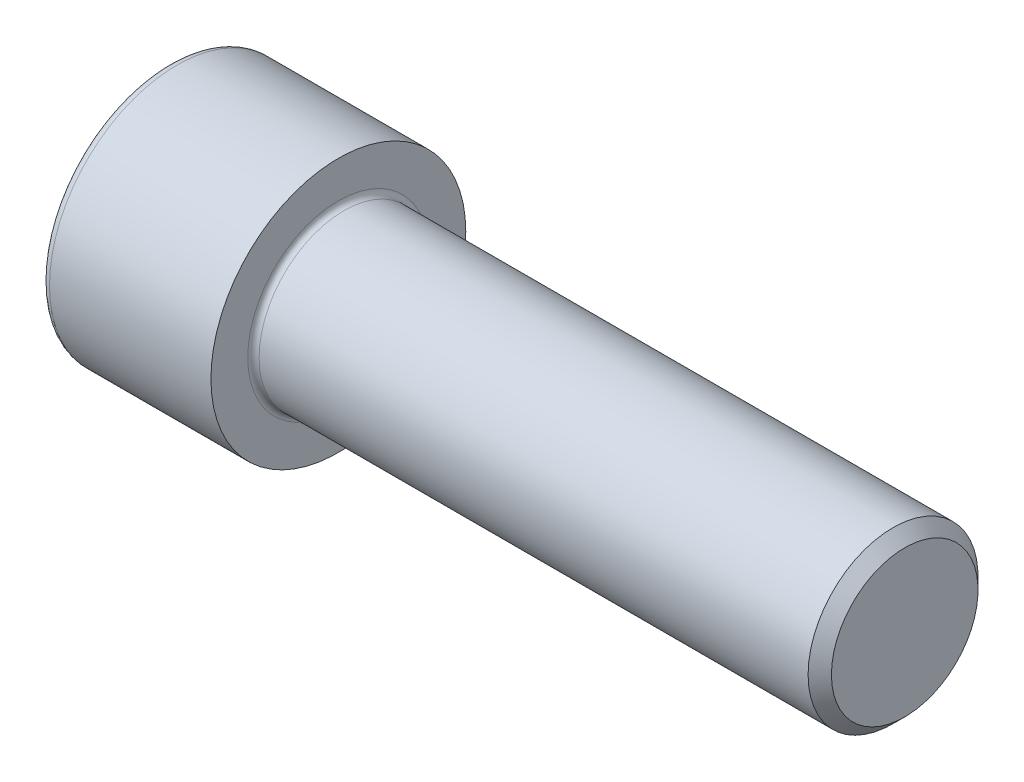
from build123d import *

# Parameters (mm, degrees)
FILLET1_R   = 0.8
FILLET2_R   = 1.2
HEX_2_DEPTH = 12.573


with BuildPart() as part:
    # BodySke → Base-Revolve (revolve)
    with BuildSketch(Plane.XY):
        Polygon((0, 0), (0, 18), (24, 18), (24, 12), (102.352, 12), (104, 10.352), (104, 0), align=None)
    revolve(axis=Axis((-31.75, 0, 0), (1, 0, 0)))

    # Fillet1
    fillet1_edges = [part.edges().sort_by_distance(p)[0] for p in [
        (24, -12, 0),
    ]]
    fillet(fillet1_edges, radius=FILLET1_R)

    # Fillet2
    fillet2_edges = [part.edges().sort_by_distance(p)[0] for p in [
        (0, -18, 0),
    ]]
    fillet(fillet2_edges, radius=FILLET2_R)

    # Sketch2 → Hex-PreBroach (revolve, cut)
    with BuildSketch(Plane.XY):
        Polygon((0, 9.6375), (12.573, 9.6375), (18.137213219, 0), (0, 0), align=None)
    revolve(axis=Axis((0, 0, 0), (1, 0, 0)), mode=Mode.SUBTRACT)

    # Sketch3 → Hex 2 (cut)
    with BuildSketch(Plane(origin=(0, 0, 0), x_dir=(0, 0.5, 0.866025404), z_dir=(-1, 0, 0))):
        Polygon((5.564213219, 9.6375), (-5.564213219, 9.6375), (-11.128426439, 0), (-5.564213219, -9.6375), (5.564213219, -9.6375), (11.128426439, 0), align=None)
    extrude(amount=-HEX_2_DEPTH, mode=Mode.SUBTRACT)


solid = part.part
